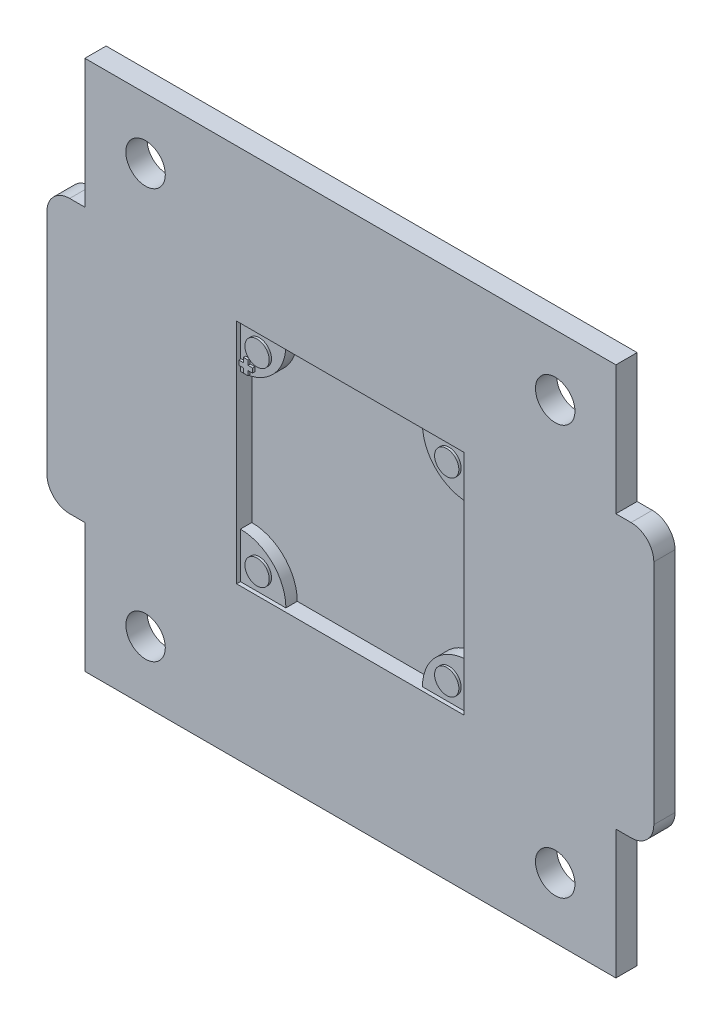
from build123d import *

# Parameters (mm, degrees)
SKETCH_1_W          = 70
SKETCH_1_H          = 70
EXTRUDE_1_DEPTH     = 2.8
SKETCH_2_W          = 30
SKETCH_2_H          = 30
CUT_EXTRUDE_1_DEPTH = 2
SKETCH_3_R          = 2.6
CUT_EXTRUDE_2_DEPTH = 3
EXTRUDE_2_DEPTH     = 2.3
SKETCH_6_R          = 1.6
EXTRUDE_3_DEPTH     = 0.3


with BuildPart() as part:
    # 草图1 → 凸台-拉伸1 (new body)
    with BuildSketch(Plane.XY):
        with BuildLine():
            Line((-2, 17), (0, 17))
            Line((0, 17), (0, 53))
            Line((0, 53), (-2, 53))
            ThreePointArc((-2, 53), (-4.121320344, 52.121320344), (-5, 50))
            Line((-5, 50), (-5, 20))
            ThreePointArc((-5, 20), (-4.121320344, 17.878679656), (-2, 17))
        make_face()
        with Locations((35, 35)):
            Rectangle(SKETCH_1_W, SKETCH_1_H)
        with BuildLine():
            Line((70, 53), (70, 17))
            Line((70, 17), (72, 17))
            ThreePointArc((72, 17), (74.121320344, 17.878679656), (75, 20))
            Line((75, 20), (75, 50))
            ThreePointArc((75, 50), (74.121320344, 52.121320344), (72, 53))
            Line((72, 53), (70, 53))
        make_face()
    extrude(amount=EXTRUDE_1_DEPTH)

    # 草图2 → 切除-拉伸1 (cut)
    with BuildSketch(Plane.XY.offset(2.8)):
        with Locations((35, 35)):
            Rectangle(SKETCH_2_W, SKETCH_2_H)
    extrude(amount=-CUT_EXTRUDE_1_DEPTH, mode=Mode.SUBTRACT)

    # 草图3 → 切除-拉伸2 (cut)
    with BuildSketch(Plane.XY.offset(2.8)):
        with Locations((8, 62)):
            Circle(SKETCH_3_R)
        with Locations((62, 62)):
            Circle(SKETCH_3_R)
        with Locations((8, 8)):
            Circle(SKETCH_3_R)
        with Locations((62, 8)):
            Circle(SKETCH_3_R)
    extrude(amount=-CUT_EXTRUDE_2_DEPTH, mode=Mode.SUBTRACT)

    # 草图4 → 凸台-拉伸2 (add)
    with BuildSketch(Plane.XY):
        with BuildLine():
            Line((20, 44), (20, 50))
            Line((20, 50), (26, 50))
            ThreePointArc((26, 50), (24.242640687, 45.757359313), (20, 44))
        make_face()
        with BuildLine():
            Line((50, 44), (50, 50))
            Line((50, 50), (44, 50))
            ThreePointArc((44, 50), (45.757359313, 45.757359313), (50, 44))
        make_face()
        with BuildLine():
            Line((50, 20), (44, 20))
            ThreePointArc((44, 20), (45.757359313, 24.242640687), (50, 26))
            Line((50, 26), (50, 20))
        make_face()
        with BuildLine():
            Line((20, 26), (20, 20))
            Line((20, 20), (26, 20))
            ThreePointArc((26, 20), (24.242640687, 24.242640687), (20, 26))
        make_face()
    extrude(amount=EXTRUDE_2_DEPTH)

    # 草图6 → 凸台-拉伸3 (add)
    with BuildSketch(Plane.XY.offset(2.3)):
        with Locations((22.5, 47.5)):
            Circle(SKETCH_6_R)
        with Locations((47.5, 47.5)):
            Circle(SKETCH_6_R)
        with Locations((47.5, 22.5)):
            Circle(SKETCH_6_R)
        with Locations((22.5, 22.5)):
            Circle(SKETCH_6_R)
        Polygon((20.1, 45.5), (20.7, 45.5), (20.7, 46.1), (21.3, 46.1), (21.3, 45.5), (21.9, 45.5), (21.9, 44.9), (21.3, 44.9), (21.3, 44.3), (20.7, 44.3), (20.7, 44.9), (20.1, 44.9), align=None)
    extrude(amount=EXTRUDE_3_DEPTH)


solid = part.part
